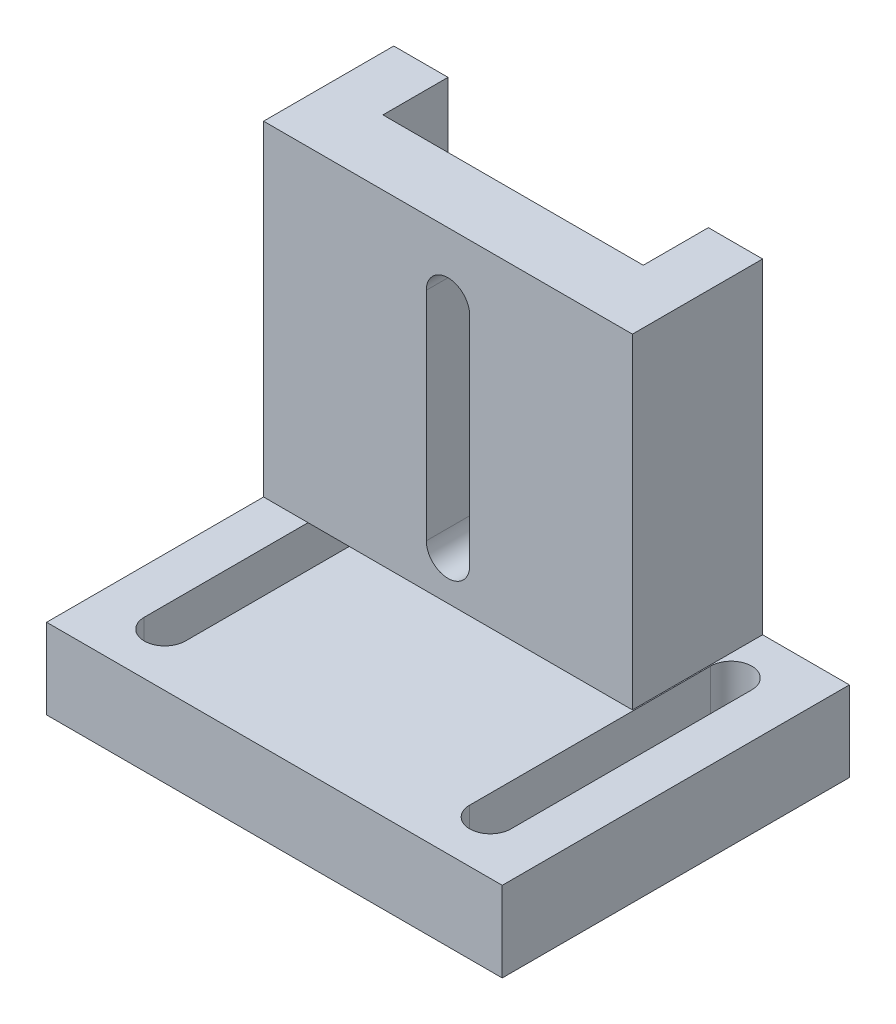
from build123d import *

# Parameters (mm, degrees)
SKETCH1_W           = 10
SKETCH1_H           = 16
BOSS_EXTRUDE1_DEPTH = 3.7
SKETCH5_W           = 5.5
SKETCH5_H           = 16
BOSS_EXTRUDE2_DEPTH = 3.7
CUT_EXTRUDE4_DEPTH  = 14.709121051
BOSS_EXTRUDE3_START = -2
SKETCH7_W           = 17
SKETCH7_H           = 15
BOSS_EXTRUDE3_DEPTH = 3
SKETCH8_W           = 2.5
SKETCH8_H           = 15
BOSS_EXTRUDE5_DEPTH = 3


with BuildPart() as part:
    # Sketch1 → Boss-Extrude1 (new body)
    with BuildSketch(Plane(origin=(0, 0, 0), x_dir=(1, 0, 0), z_dir=(0, 1, 0))):
        Rectangle(SKETCH1_W, SKETCH1_H)
    extrude(amount=BOSS_EXTRUDE1_DEPTH)

    # Sketch5 → Boss-Extrude2 (add)
    with BuildSketch(Plane.XZ):
        with Locations((-7.75, 0)):
            Rectangle(SKETCH5_W, SKETCH5_H)
    boss_extrude2 = extrude(amount=-BOSS_EXTRUDE2_DEPTH)

    # Sketch6 → Cut-Extrude4 (cut, through all)
    with BuildSketch(Plane(origin=(0, 3.7, 0), x_dir=(1, 0, 0), z_dir=(0, 1, 0))):
        with BuildLine():
            Line((-6.55, 5.55), (-6.55, -5.55))
            ThreePointArc((-6.55, -5.55), (-7.5, -6.5), (-8.45, -5.55))
            Line((-8.45, -5.55), (-8.45, 5.55))
            ThreePointArc((-8.45, 5.55), (-7.5, 6.5), (-6.55, 5.55))
        make_face()
    cut_extrude4 = extrude(amount=-CUT_EXTRUDE4_DEPTH, mode=Mode.SUBTRACT)

    # Mirror1: Boss-Extrude2, Cut-Extrude4 across plane
    add(boss_extrude2.mirror(Plane(origin=(0, 0, 0), x_dir=(0, 0, 1), z_dir=(1, 0, 0))))
    add(cut_extrude4.mirror(Plane(origin=(0, 0, 0), x_dir=(0, 0, 1), z_dir=(1, 0, 0))), mode=Mode.SUBTRACT)



with BuildPart() as body_2:
    # Sketch7 → Boss-Extrude3 (new body)
    with BuildSketch(Plane.XY.offset(BOSS_EXTRUDE3_START)):
        with Locations((-2, 11.2)):
            Rectangle(SKETCH7_W, SKETCH7_H)
        with BuildLine():
            Line((-3, 15.7), (-3, 5.7))
            ThreePointArc((-3, 5.7), (-2, 4.7), (-1, 5.7))
            Line((-1, 5.7), (-1, 15.7))
            ThreePointArc((-1, 15.7), (-2, 16.7), (-3, 15.7))
        make_face(mode=Mode.SUBTRACT)
    extrude(amount=-BOSS_EXTRUDE3_DEPTH)


with BuildPart() as part_1:
    add(part.part)

    add(body_2.part)  # Boss-Extrude5 merges body 2
    # Sketch8 → Boss-Extrude5 (add)
    with BuildSketch(Plane(origin=(0, 0, -5), x_dir=(-1, 0, 0), z_dir=(0, 0, -1))):
        with Locations((-5.25, 11.2)):
            Rectangle(SKETCH8_W, SKETCH8_H)
        with Locations((9.25, 11.2)):
            Rectangle(SKETCH8_W, SKETCH8_H)
    extrude(amount=BOSS_EXTRUDE5_DEPTH)


solid = part_1.part
